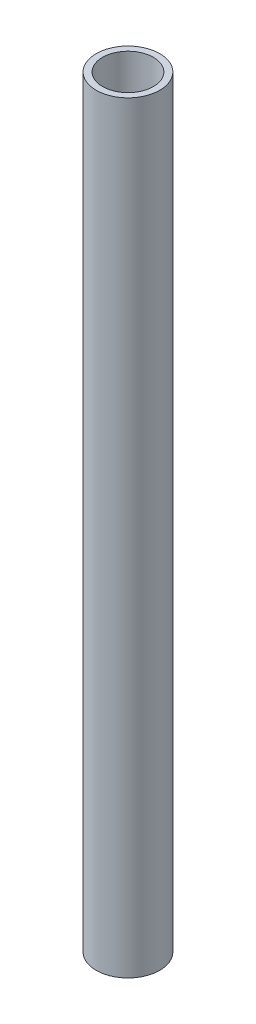
from build123d import *

# Parameters (mm, degrees)
SKETCH2_R           = 10
SKETCH2_R_2         = 8
BOSS_EXTRUDE1_DEPTH = 240


with BuildPart() as part:
    # Sketch2 → Boss-Extrude1 (new body)
    with BuildSketch(Plane(origin=(0, 0, 0), x_dir=(1, 0, 0), z_dir=(0, 1, 0))):
        Circle(SKETCH2_R)
        Circle(SKETCH2_R_2, mode=Mode.SUBTRACT)
    extrude(amount=BOSS_EXTRUDE1_DEPTH)


solid = part.part
